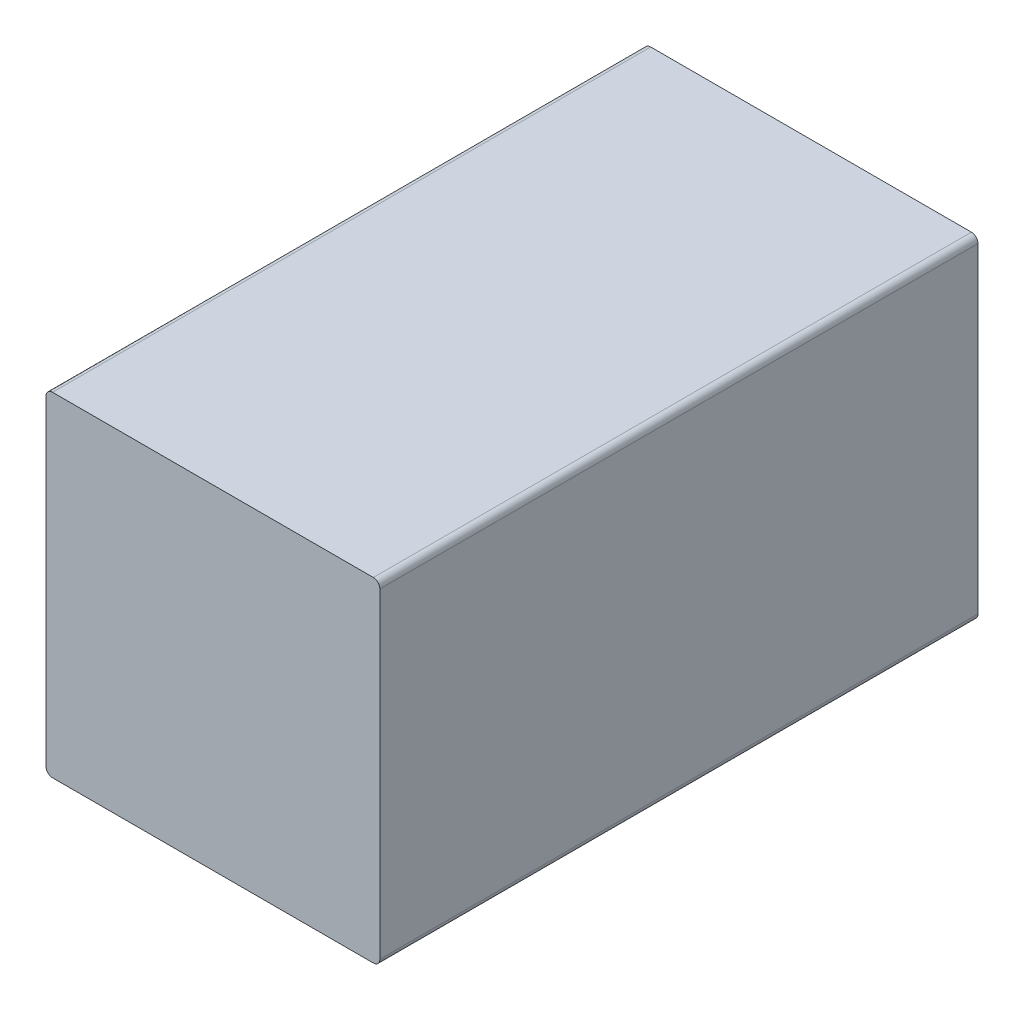
from build123d import *

# Parameters (mm, degrees)
SKETCH1_W           = 50.8
SKETCH1_H           = 50.8
BOSS_EXTRUDE1_DEPTH = 1
SKETCH1_3_W         = 50.8
SKETCH1_3_H         = 50.8
SKETCH1_3_W_2       = 46.8
SKETCH1_3_H_2       = 46.8
BOSS_EXTRUDE2_DEPTH = 90
FILLET1_R           = 1


with BuildPart() as part:
    # Sketch1 → Boss-Extrude1 (new body)
    with BuildSketch(Plane.XY):
        with Locations((25.4, 25.4)):
            Rectangle(SKETCH1_W, SKETCH1_H)
    extrude(amount=BOSS_EXTRUDE1_DEPTH)

    # Sketch1_3 → Boss-Extrude2 (add)
    with BuildSketch(Plane.XY):
        with Locations((25.4, 25.4)):
            Rectangle(SKETCH1_3_W, SKETCH1_3_H)
        with Locations((25.4, 25.4)):
            Rectangle(SKETCH1_3_W_2, SKETCH1_3_H_2, mode=Mode.SUBTRACT)
    extrude(amount=-BOSS_EXTRUDE2_DEPTH)

    # Fillet1
    fillet1_edges = [part.edges().sort_by_distance(p)[0] for p in [
        (0, 50.8, -44.5),
        (50.8, 50.8, -44.5),
        (50.8, 0, -44.5),
        (0, 0, -44.5),
    ]]
    fillet(fillet1_edges, radius=FILLET1_R)


solid = part.part
